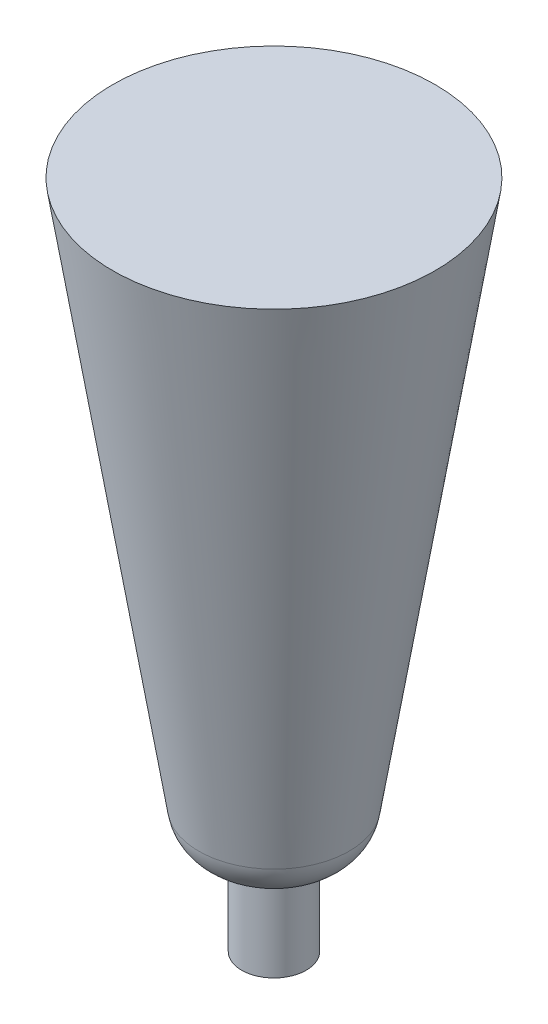
from build123d import *


with BuildPart() as part:
    # Sketch2 → Revolve6 (revolve)
    with BuildSketch(Plane.XY):
        with BuildLine():
            Line((0, 0), (3.81, 0))
            Line((3.81, 0), (3.81, 10.16))
            ThreePointArc((3.81, 10.16), (7.144757629, 11.518401002), (8.867367053, 14.680438083))
            Line((8.867367053, 14.680438083), (9.13615193, 16.38662103))
            Line((9.13615193, 16.38662103), (19, 79))
            Line((19, 79), (0, 79))
            Line((0, 79), (0, 0))
        make_face()
    revolve(axis=Axis((0, 0, 0), (0, 1, 0)))


solid = part.part
